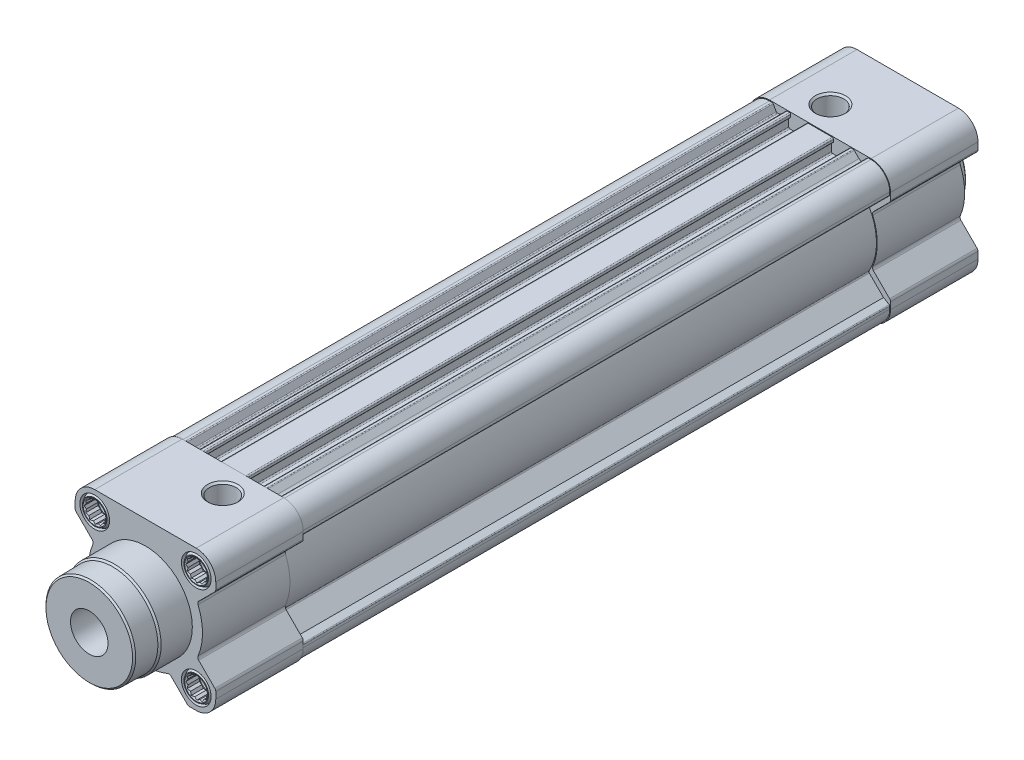
from build123d import *

# Parameters (mm, degrees)
BOSS_EXTRUDE1_DEPTH  = 28
BOSS_EXTRUDE2_DEPTH  = 188
SKETCH3_W            = 54
SKETCH3_H            = 54
CUT_EXTRUDE1_DEPTH   = 188
BOSS_EXTRUDE3_DEPTH  = 28
SKETCH7_W            = 21
SKETCH7_H            = 4.75
LPATTERN1_COUNT      = 2
LPATTERN1_PITCH      = 32.5
LPATTERN1_COUNT_DIR2 = 2
LPATTERN1_PITCH_DIR2 = 32.5
LPATTERN2_COUNT      = 2
LPATTERN2_PITCH      = 32.5
LPATTERN2_COUNT_DIR2 = 2
LPATTERN2_PITCH_DIR2 = 32.5
CUT_EXTRUDE2_DEPTH   = 4
LPATTERN3_COUNT      = 2
LPATTERN3_PITCH      = 32.5
LPATTERN3_COUNT_DIR2 = 2
LPATTERN3_PITCH_DIR2 = 32.5
LPATTERN4_COUNT      = 2
LPATTERN4_PITCH      = 32.5
LPATTERN4_COUNT_DIR2 = 2
LPATTERN4_PITCH_DIR2 = 32.5
SKETCH17_W           = 21
SKETCH17_H           = 4.75
LPATTERN5_COUNT      = 2
LPATTERN5_PITCH      = 32.5
LPATTERN5_COUNT_DIR2 = 2
LPATTERN5_PITCH_DIR2 = 32.5
LPATTERN6_COUNT      = 2
LPATTERN6_PITCH      = 32.5
LPATTERN6_COUNT_DIR2 = 2
LPATTERN6_PITCH_DIR2 = 32.5
LPATTERN7_COUNT      = 2
LPATTERN7_PITCH      = 32.5
LPATTERN7_COUNT_DIR2 = 2
LPATTERN7_PITCH_DIR2 = 32.5
CUT_EXTRUDE3_DEPTH   = 4
LPATTERN8_COUNT      = 2
LPATTERN8_PITCH      = 32.5
LPATTERN8_COUNT_DIR2 = 2
LPATTERN8_PITCH_DIR2 = 32.5


with BuildPart() as part:
    # Sketch1 → Boss-Extrude1 (new body)
    with BuildSketch(Plane.XY.offset(-28)):
        with BuildLine():
            Line((-22.207106781, 13.368272016), (-17.028937595, 8.190102831))
            ThreePointArc((-17.028937595, 8.190102831), (-16.754625387, 7.674873005), (-16.814691422, 7.094268982))
            ThreePointArc((-16.814691422, 7.094268982), (-18.25, 0), (-16.814691422, -7.094268982))
            ThreePointArc((-16.814691422, -7.094268982), (-16.754625387, -7.674873005), (-17.028937595, -8.190102831))
            Line((-17.028937595, -8.190102831), (-22.207106781, -13.368272016))
            ThreePointArc((-22.207106781, -13.368272016), (-22.423879533, -13.692695365), (-22.5, -14.075378798))
            Line((-22.5, -14.075378798), (-22.5, -16.25))
            ThreePointArc((-22.5, -16.25), (-20.669417382, -20.669417382), (-16.25, -22.5))
            Line((-16.25, -22.5), (-14.075378798, -22.5))
            ThreePointArc((-14.075378798, -22.5), (-13.692695365, -22.423879533), (-13.368272016, -22.207106781))
            Line((-13.368272016, -22.207106781), (-8.190102831, -17.028937595))
            ThreePointArc((-8.190102831, -17.028937595), (-7.674873005, -16.754625387), (-7.094268982, -16.814691422))
            ThreePointArc((-7.094268982, -16.814691422), (0, -18.25), (7.094268982, -16.814691422))
            ThreePointArc((7.094268982, -16.814691422), (7.674873005, -16.754625387), (8.190102831, -17.028937595))
            Line((8.190102831, -17.028937595), (13.368272016, -22.207106781))
            ThreePointArc((13.368272016, -22.207106781), (13.692695365, -22.423879533), (14.075378798, -22.5))
            Line((14.075378798, -22.5), (16.25, -22.5))
            ThreePointArc((16.25, -22.5), (20.669417382, -20.669417382), (22.5, -16.25))
            Line((22.5, -16.25), (22.5, -14.075378798))
            ThreePointArc((22.5, -14.075378798), (22.423879533, -13.692695365), (22.207106781, -13.368272016))
            Line((22.207106781, -13.368272016), (17.028937595, -8.190102831))
            ThreePointArc((17.028937595, -8.190102831), (16.754625387, -7.674873005), (16.814691422, -7.094268982))
            ThreePointArc((16.814691422, -7.094268982), (18.25, 0), (16.814691422, 7.094268982))
            ThreePointArc((16.814691422, 7.094268982), (16.754625387, 7.674873005), (17.028937595, 8.190102831))
            Line((17.028937595, 8.190102831), (22.207106781, 13.368272016))
            ThreePointArc((22.207106781, 13.368272016), (22.423879533, 13.692695365), (22.5, 14.075378798))
            Line((22.5, 14.075378798), (22.5, 16.25))
            ThreePointArc((22.5, 16.25), (20.669417382, 20.669417382), (16.25, 22.5))
            Line((16.25, 22.5), (-16.25, 22.5))
            ThreePointArc((-16.25, 22.5), (-20.669417382, 20.669417382), (-22.5, 16.25))
            Line((-22.5, 16.25), (-22.5, 14.075378798))
            ThreePointArc((-22.5, 14.075378798), (-22.423879533, 13.692695365), (-22.207106781, 13.368272016))
        make_face()
    extrude(amount=BOSS_EXTRUDE1_DEPTH)

    # Sketch2 → Boss-Extrude2 (add)
    with BuildSketch(Plane.XY.offset(-28)):
        with BuildLine():
            Line((-22.25, 13.764718626), (-16.641027679, 8.155746305))
            ThreePointArc((-16.641027679, 8.155746305), (-16.502437125, 7.890478462), (-16.540180506, 7.59357813))
            ThreePointArc((-16.540180506, 7.59357813), (-18.2, 0), (-16.540180506, -7.59357813))
            ThreePointArc((-16.540180506, -7.59357813), (-16.502437125, -7.890478462), (-16.641027679, -8.155746305))
            Line((-16.641027679, -8.155746305), (-22.25, -13.764718626))
            Line((-22.25, -13.764718626), (-22.25, -16.25))
            ThreePointArc((-22.25, -16.25), (-20.492640687, -20.492640687), (-16.25, -22.25))
            Line((-16.25, -22.25), (-13.764718626, -22.25))
            Line((-13.764718626, -22.25), (-8.155746305, -16.641027679))
            ThreePointArc((-8.155746305, -16.641027679), (-7.890478462, -16.502437125), (-7.59357813, -16.540180506))
            ThreePointArc((-7.59357813, -16.540180506), (0, -18.2), (7.59357813, -16.540180506))
            ThreePointArc((7.59357813, -16.540180506), (7.890478462, -16.502437125), (8.155746305, -16.641027679))
            Line((8.155746305, -16.641027679), (13.764718626, -22.25))
            Line((13.764718626, -22.25), (16.25, -22.25))
            ThreePointArc((16.25, -22.25), (20.492640687, -20.492640687), (22.25, -16.25))
            Line((22.25, -16.25), (22.25, -13.764718626))
            Line((22.25, -13.764718626), (16.641027679, -8.155746305))
            ThreePointArc((16.641027679, -8.155746305), (16.502437125, -7.890478462), (16.540180506, -7.59357813))
            ThreePointArc((16.540180506, -7.59357813), (18.2, 0), (16.540180506, 7.59357813))
            ThreePointArc((16.540180506, 7.59357813), (16.502437125, 7.890478462), (16.641027679, 8.155746305))
            Line((16.641027679, 8.155746305), (22.25, 13.764718626))
            Line((22.25, 13.764718626), (22.25, 16.25))
            ThreePointArc((22.25, 16.25), (20.492640687, 20.492640687), (16.25, 22.25))
            Line((16.25, 22.25), (-16.25, 22.25))
            ThreePointArc((-16.25, 22.25), (-20.492640687, 20.492640687), (-22.25, 16.25))
            Line((-22.25, 16.25), (-22.25, 13.764718626))
        make_face()
    extrude(amount=-BOSS_EXTRUDE2_DEPTH)

    # Sketch3 → Cut-Extrude1 (cut)
    with BuildSketch(Plane.XY.offset(-28)):
        Rectangle(SKETCH3_W, SKETCH3_H)
        with BuildLine():
            Line((-22.05, 15.063462134), (-20.287966634, 14.046151696))
            ThreePointArc((-20.287966634, 14.046151696), (-20.244462062, 14.017082871), (-20.205123922, 13.982584247))
            Line((-20.205123922, 13.982584247), (-15.725547462, 9.503007788))
            ThreePointArc((-15.725547462, 9.503007788), (-15.58358527, 9.21626987), (-15.644530559, 8.902171846))
            ThreePointArc((-15.644530559, 8.902171846), (-18, 0), (-15.644530559, -8.902171846))
            ThreePointArc((-15.644530559, -8.902171846), (-15.58358527, -9.21626987), (-15.725547462, -9.503007788))
            Line((-15.725547462, -9.503007788), (-20.242360871, -14.019821197))
            Line((-20.242360871, -14.019821197), (-22.05, -15.063462134))
            ThreePointArc((-22.05, -15.063462134), (-22.196410162, -15.209872296), (-22.25, -15.409872296))
            Line((-22.25, -15.409872296), (-22.25, -16.25))
            ThreePointArc((-22.25, -16.25), (-20.492640687, -20.492640687), (-16.25, -22.25))
            Line((-16.25, -22.25), (-15.409872296, -22.25))
            ThreePointArc((-15.409872296, -22.25), (-15.209872296, -22.196410162), (-15.063462134, -22.05))
            Line((-15.063462134, -22.05), (-14.046151696, -20.287966634))
            ThreePointArc((-14.046151696, -20.287966634), (-14.017082871, -20.244462062), (-13.982584247, -20.205123922))
            Line((-13.982584247, -20.205123922), (-9.503007788, -15.725547462))
            ThreePointArc((-9.503007788, -15.725547462), (-9.21626987, -15.58358527), (-8.902171846, -15.644530559))
            ThreePointArc((-8.902171846, -15.644530559), (0, -18), (8.902171846, -15.644530559))
            ThreePointArc((8.902171846, -15.644530559), (9.21626987, -15.58358527), (9.503007788, -15.725547462))
            Line((9.503007788, -15.725547462), (13.982584247, -20.205123922))
            ThreePointArc((13.982584247, -20.205123922), (14.017082871, -20.244462062), (14.046151696, -20.287966634))
            Line((14.046151696, -20.287966634), (15.063462134, -22.05))
            ThreePointArc((15.063462134, -22.05), (15.209872296, -22.196410162), (15.409872296, -22.25))
            Line((15.409872296, -22.25), (16.25, -22.25))
            ThreePointArc((16.25, -22.25), (20.492640687, -20.492640687), (22.25, -16.25))
            Line((22.25, -16.25), (22.25, -15.409872296))
            ThreePointArc((22.25, -15.409872296), (22.196410162, -15.209872296), (22.05, -15.063462134))
            Line((22.05, -15.063462134), (20.242360871, -14.019821197))
            Line((20.242360871, -14.019821197), (15.725547462, -9.503007788))
            ThreePointArc((15.725547462, -9.503007788), (15.58358527, -9.21626987), (15.644530559, -8.902171846))
            ThreePointArc((15.644530559, -8.902171846), (18, 0), (15.644530559, 8.902171846))
            ThreePointArc((15.644530559, 8.902171846), (15.58358527, 9.21626987), (15.725547462, 9.503007788))
            Line((15.725547462, 9.503007788), (20.205123922, 13.982584247))
            ThreePointArc((20.205123922, 13.982584247), (20.244462062, 14.017082871), (20.287966634, 14.046151696))
            Line((20.287966634, 14.046151696), (22.05, 15.063462134))
            ThreePointArc((22.05, 15.063462134), (22.196410162, 15.209872296), (22.25, 15.409872296))
            Line((22.25, 15.409872296), (22.25, 16.25))
            ThreePointArc((22.25, 16.25), (20.492640687, 20.492640687), (16.25, 22.25))
            Line((16.25, 22.25), (15.409872296, 22.25))
            ThreePointArc((15.409872296, 22.25), (15.209872296, 22.196410162), (15.063462134, 22.05))
            Line((15.063462134, 22.05), (14.081966677, 20.35))
            ThreePointArc((14.081966677, 20.35), (13.935556515, 20.203589838), (13.735556515, 20.15))
            Line((13.735556515, 20.15), (13.471320344, 20.15))
            ThreePointArc((13.471320344, 20.15), (12.897295195, 20.264180701), (12.410660172, 20.589339828))
            Line((12.410660172, 20.589339828), (10.867157288, 22.132842712))
            ThreePointArc((10.867157288, 22.132842712), (10.737387948, 22.219551813), (10.584314575, 22.25))
            Line((10.584314575, 22.25), (9.85, 22.25))
            ThreePointArc((9.85, 22.25), (9.567157288, 22.132842712), (9.45, 21.85))
            Line((9.45, 21.85), (9.45, 21.15))
            ThreePointArc((9.45, 21.15), (9.508578644, 21.008578644), (9.65, 20.95))
            Line((9.65, 20.95), (9.9, 20.95))
            ThreePointArc((9.9, 20.95), (10.041421356, 20.891421356), (10.1, 20.75))
            Line((10.1, 20.75), (10.1, 18.15))
            ThreePointArc((10.1, 18.15), (9.982842712, 17.867157288), (9.7, 17.75))
            Line((9.7, 17.75), (4, 17.75))
            ThreePointArc((4, 17.75), (3.717157288, 17.867157288), (3.6, 18.15))
            Line((3.6, 18.15), (3.6, 20.75))
            ThreePointArc((3.6, 20.75), (3.658578644, 20.891421356), (3.8, 20.95))
            Line((3.8, 20.95), (4.05, 20.95))
            ThreePointArc((4.05, 20.95), (4.191421356, 21.008578644), (4.25, 21.15))
            Line((4.25, 21.15), (4.25, 21.85))
            ThreePointArc((4.25, 21.85), (4.132842712, 22.132842712), (3.85, 22.25))
            Line((3.85, 22.25), (-3.85, 22.25))
            ThreePointArc((-3.85, 22.25), (-4.132842712, 22.132842712), (-4.25, 21.85))
            Line((-4.25, 21.85), (-4.25, 21.15))
            ThreePointArc((-4.25, 21.15), (-4.191421356, 21.008578644), (-4.05, 20.95))
            Line((-4.05, 20.95), (-3.8, 20.95))
            ThreePointArc((-3.8, 20.95), (-3.658578644, 20.891421356), (-3.6, 20.75))
            Line((-3.6, 20.75), (-3.6, 18.15))
            ThreePointArc((-3.6, 18.15), (-3.717157288, 17.867157288), (-4, 17.75))
            Line((-4, 17.75), (-9.7, 17.75))
            ThreePointArc((-9.7, 17.75), (-9.982842712, 17.867157288), (-10.1, 18.15))
            Line((-10.1, 18.15), (-10.1, 20.75))
            ThreePointArc((-10.1, 20.75), (-10.041421356, 20.891421356), (-9.9, 20.95))
            Line((-9.9, 20.95), (-9.65, 20.95))
            ThreePointArc((-9.65, 20.95), (-9.508578644, 21.008578644), (-9.45, 21.15))
            Line((-9.45, 21.15), (-9.45, 21.85))
            ThreePointArc((-9.45, 21.85), (-9.567157288, 22.132842712), (-9.85, 22.25))
            Line((-9.85, 22.25), (-10.584314575, 22.25))
            ThreePointArc((-10.584314575, 22.25), (-10.737387948, 22.219551813), (-10.867157288, 22.132842712))
            Line((-10.867157288, 22.132842712), (-12.410660172, 20.589339828))
            ThreePointArc((-12.410660172, 20.589339828), (-12.897295195, 20.264180701), (-13.471320344, 20.15))
            Line((-13.471320344, 20.15), (-13.735556515, 20.15))
            ThreePointArc((-13.735556515, 20.15), (-13.935556515, 20.203589838), (-14.081966677, 20.35))
            Line((-14.081966677, 20.35), (-15.063462134, 22.05))
            ThreePointArc((-15.063462134, 22.05), (-15.209872296, 22.196410162), (-15.409872296, 22.25))
            Line((-15.409872296, 22.25), (-16.25, 22.25))
            ThreePointArc((-16.25, 22.25), (-20.492640687, 20.492640687), (-22.25, 16.25))
            Line((-22.25, 16.25), (-22.25, 15.409872296))
            ThreePointArc((-22.25, 15.409872296), (-22.196410162, 15.209872296), (-22.05, 15.063462134))
        make_face(mode=Mode.SUBTRACT)
    extrude(amount=-CUT_EXTRUDE1_DEPTH, mode=Mode.SUBTRACT)

    # Sketch4 → Boss-Extrude3 (add)
    with BuildSketch(Plane.XY.offset(-244)):
        with BuildLine():
            Line((-22.207106781, 13.368272016), (-17.028937595, 8.190102831))
            ThreePointArc((-17.028937595, 8.190102831), (-16.754625387, 7.674873005), (-16.814691422, 7.094268982))
            ThreePointArc((-16.814691422, 7.094268982), (-18.25, 0), (-16.814691422, -7.094268982))
            ThreePointArc((-16.814691422, -7.094268982), (-16.754625387, -7.674873005), (-17.028937595, -8.190102831))
            Line((-17.028937595, -8.190102831), (-22.207106781, -13.368272016))
            ThreePointArc((-22.207106781, -13.368272016), (-22.423879533, -13.692695365), (-22.5, -14.075378798))
            Line((-22.5, -14.075378798), (-22.5, -16.25))
            ThreePointArc((-22.5, -16.25), (-20.669417382, -20.669417382), (-16.25, -22.5))
            Line((-16.25, -22.5), (-14.075378798, -22.5))
            ThreePointArc((-14.075378798, -22.5), (-13.692695365, -22.423879533), (-13.368272016, -22.207106781))
            Line((-13.368272016, -22.207106781), (-8.190102831, -17.028937595))
            ThreePointArc((-8.190102831, -17.028937595), (-7.674873005, -16.754625387), (-7.094268982, -16.814691422))
            ThreePointArc((-7.094268982, -16.814691422), (0, -18.25), (7.094268982, -16.814691422))
            ThreePointArc((7.094268982, -16.814691422), (7.674873005, -16.754625387), (8.190102831, -17.028937595))
            Line((8.190102831, -17.028937595), (13.368272016, -22.207106781))
            ThreePointArc((13.368272016, -22.207106781), (13.692695365, -22.423879533), (14.075378798, -22.5))
            Line((14.075378798, -22.5), (16.25, -22.5))
            ThreePointArc((16.25, -22.5), (20.669417382, -20.669417382), (22.5, -16.25))
            Line((22.5, -16.25), (22.5, -14.075378798))
            ThreePointArc((22.5, -14.075378798), (22.423879533, -13.692695365), (22.207106781, -13.368272016))
            Line((22.207106781, -13.368272016), (17.028937595, -8.190102831))
            ThreePointArc((17.028937595, -8.190102831), (16.754625387, -7.674873005), (16.814691422, -7.094268982))
            ThreePointArc((16.814691422, -7.094268982), (18.25, 0), (16.814691422, 7.094268982))
            ThreePointArc((16.814691422, 7.094268982), (16.754625387, 7.674873005), (17.028937595, 8.190102831))
            Line((17.028937595, 8.190102831), (22.207106781, 13.368272016))
            ThreePointArc((22.207106781, 13.368272016), (22.423879533, 13.692695365), (22.5, 14.075378798))
            Line((22.5, 14.075378798), (22.5, 16.25))
            ThreePointArc((22.5, 16.25), (20.669417382, 20.669417382), (16.25, 22.5))
            Line((16.25, 22.5), (-16.25, 22.5))
            ThreePointArc((-16.25, 22.5), (-20.669417382, 20.669417382), (-22.5, 16.25))
            Line((-22.5, 16.25), (-22.5, 14.075378798))
            ThreePointArc((-22.5, 14.075378798), (-22.423879533, 13.692695365), (-22.207106781, 13.368272016))
        make_face()
    extrude(amount=BOSS_EXTRUDE3_DEPTH)

    # Sketch5 → Revolve1 (revolve)
    with BuildSketch(Plane(origin=(0, 0, 0), x_dir=(0, 0, -1), z_dir=(1, 0, 0))):
        Polygon((-18, 0), (-18, 13.869087013), (-17.5, 14.369087013), (-10.508882578, 14.491117422), (-10, 15), (0, 15), (0, 0), align=None)
    revolve(axis=Axis((0, 0, 0), (0, 0, 1)))

    # Sketch6 → Cut-Revolve1 (revolve, cut)
    with BuildSketch(Plane(origin=(5.25, 0, 0), x_dir=(0, 0, -1), z_dir=(1, 0, 0))):
        Polygon((19.5, 22.5), (24.364, 22.5), (23.783, 21.919), (23.783, 0), (19.5, 0), align=None)
    revolve(axis=Axis((5.25, 0, -19.5), (0, 1, 0)), mode=Mode.SUBTRACT)

    # Sketch7 → Cut-Revolve2 (revolve, cut)
    with BuildSketch(Plane(origin=(16.25, 0, 0), x_dir=(0, 0, -1), z_dir=(1, 0, 0))):
        with Locations((10.5, 18.625)):
            Rectangle(SKETCH7_W, SKETCH7_H)
    cut_revolve2 = revolve(axis=Axis((16.25, 16.25, -21), (0, 0, 1)), mode=Mode.SUBTRACT)

    # LPattern1: Cut-Revolve2 2 × 2
    with Locations(*[(-i * LPATTERN1_PITCH, -j * LPATTERN1_PITCH_DIR2, 0) for i in range(LPATTERN1_COUNT) for j in range(LPATTERN1_COUNT_DIR2) if (i, j) != (0, 0)]):
        add(cut_revolve2, mode=Mode.SUBTRACT)

    # Sketch9 → Revolve2 (revolve)
    with BuildSketch(Plane(origin=(16.25, 0, 0), x_dir=(0, 0, -1), z_dir=(1, 0, 0))):
        Polygon((0, 16.25), (0, 20.172649731), (1, 20.75), (21, 20.75), (21, 16.25), align=None)
    revolve2 = revolve(axis=Axis((16.25, 16.25, -21), (0, 0, 1)))

    # LPattern2: Revolve2 2 × 2
    with Locations(*[(-i * LPATTERN2_PITCH, -j * LPATTERN2_PITCH_DIR2, 0) for i in range(LPATTERN2_COUNT) for j in range(LPATTERN2_COUNT_DIR2) if (i, j) != (0, 0)]):
        add(revolve2)

    # Sketch11 → Cut-Revolve3 (revolve, cut)
    with BuildSketch(Plane(origin=(16.25, 0, 0), x_dir=(0, 0, -1), z_dir=(1, 0, 0))):
        Polygon((0, 16.25), (0, 19.95), (0.404145188, 19.25), (5.5, 19.25), (6.0415, 18.7085), (18.7, 18.7085), (20.119415637, 16.25), align=None)
    cut_revolve3 = revolve(axis=Axis((16.25, 16.25, -20.119415637), (0, 0, 1)), mode=Mode.SUBTRACT)

    # Sketch12 → Cut-Extrude2 (cut, symmetric)
    with BuildSketch(Plane.XY):
        Polygon((12.785898385, 16.25), (13.25, 15.446152423), (13.25, 14.517949192), (14.053847577, 14.053847577), (14.517949192, 13.25), (15.446152423, 13.25), (16.25, 12.785898385), (17.053847577, 13.25), (17.982050808, 13.25), (18.446152423, 14.053847577), (19.25, 14.517949192), (19.25, 15.446152423), (19.714101615, 16.25), (19.25, 17.053847577), (19.25, 17.982050808), (18.446152423, 18.446152423), (17.982050808, 19.25), (17.053847577, 19.25), (16.25, 19.714101615), (15.446152423, 19.25), (14.517949192, 19.25), (14.053847577, 18.446152423), (13.25, 17.982050808), (13.25, 17.053847577), align=None)
    cut_extrude2 = extrude(amount=CUT_EXTRUDE2_DEPTH, both=True, mode=Mode.SUBTRACT)

    # LPattern3: Cut-Revolve3 2 × 2
    with Locations(*[(-i * LPATTERN3_PITCH, -j * LPATTERN3_PITCH_DIR2, 0) for i in range(LPATTERN3_COUNT) for j in range(LPATTERN3_COUNT_DIR2) if (i, j) != (0, 0)]):
        add(cut_revolve3, mode=Mode.SUBTRACT)

    # LPattern4: Cut-Extrude2 2 × 2
    with Locations(*[(-i * LPATTERN4_PITCH, -j * LPATTERN4_PITCH_DIR2, 0) for i in range(LPATTERN4_COUNT) for j in range(LPATTERN4_COUNT_DIR2) if (i, j) != (0, 0)]):
        add(cut_extrude2, mode=Mode.SUBTRACT)

    # Sketch15 → Revolve3 (revolve)
    with BuildSketch(Plane(origin=(0, 0, 0), x_dir=(0, 0, -1), z_dir=(1, 0, 0))):
        Polygon((244, 0), (244, 15), (247.5, 15), (248, 14.5), (248, 0), align=None)
    revolve(axis=Axis((0, 0, -248), (0, 0, 1)))

    # Sketch16 → Cut-Revolve4 (revolve, cut)
    with BuildSketch(Plane(origin=(-5.25, 0, 0), x_dir=(0, 0, -1), z_dir=(1, 0, 0))):
        Polygon((224.5, 22.5), (229.364, 22.5), (228.783, 21.919), (228.783, 0), (224.5, 0), align=None)
    revolve(axis=Axis((-5.25, 0, -224.5), (0, 1, 0)), mode=Mode.SUBTRACT)

    # Sketch17 → Cut-Revolve5 (revolve, cut)
    with BuildSketch(Plane(origin=(16.25, 0, 0), x_dir=(0, 0, -1), z_dir=(1, 0, 0))):
        with Locations((233.5, 18.625)):
            Rectangle(SKETCH17_W, SKETCH17_H)
    cut_revolve5 = revolve(axis=Axis((16.25, 16.25, -244), (0, 0, 1)), mode=Mode.SUBTRACT)

    # LPattern5: Cut-Revolve5 2 × 2
    with Locations(*[(-i * LPATTERN5_PITCH, -j * LPATTERN5_PITCH_DIR2, 0) for i in range(LPATTERN5_COUNT) for j in range(LPATTERN5_COUNT_DIR2) if (i, j) != (0, 0)]):
        add(cut_revolve5, mode=Mode.SUBTRACT)

    # Sketch19 → Revolve4 (revolve)
    with BuildSketch(Plane(origin=(16.25, 0, 0), x_dir=(0, 0, -1), z_dir=(1, 0, 0))):
        Polygon((223, 16.25), (223, 20.75), (243, 20.75), (244, 20.172649731), (244, 16.25), align=None)
    revolve4 = revolve(axis=Axis((16.25, 16.25, -244), (0, 0, 1)))

    # LPattern6: Revolve4 2 × 2
    with Locations(*[(-i * LPATTERN6_PITCH, -j * LPATTERN6_PITCH_DIR2, 0) for i in range(LPATTERN6_COUNT) for j in range(LPATTERN6_COUNT_DIR2) if (i, j) != (0, 0)]):
        add(revolve4)

    # Sketch21 → Cut-Revolve6 (revolve, cut)
    with BuildSketch(Plane(origin=(16.25, 0, 0), x_dir=(0, 0, -1), z_dir=(1, 0, 0))):
        Polygon((223.880584363, 16.25), (225.3, 18.7085), (237.9585, 18.7085), (238.5, 19.25), (243.595854812, 19.25), (244, 19.95), (244, 16.25), align=None)
    cut_revolve6 = revolve(axis=Axis((16.25, 16.25, -244), (0, 0, 1)), mode=Mode.SUBTRACT)

    # LPattern7: Cut-Revolve6 2 × 2
    with Locations(*[(-i * LPATTERN7_PITCH, -j * LPATTERN7_PITCH_DIR2, 0) for i in range(LPATTERN7_COUNT) for j in range(LPATTERN7_COUNT_DIR2) if (i, j) != (0, 0)]):
        add(cut_revolve6, mode=Mode.SUBTRACT)

    # Sketch23 → Cut-Extrude3 (cut, symmetric)
    with BuildSketch(Plane.XY.offset(-244)):
        Polygon((12.785898385, 16.25), (13.25, 15.446152423), (13.25, 14.517949192), (14.053847577, 14.053847577), (14.517949192, 13.25), (15.446152423, 13.25), (16.25, 12.785898385), (17.053847577, 13.25), (17.982050808, 13.25), (18.446152423, 14.053847577), (19.25, 14.517949192), (19.25, 15.446152423), (19.714101615, 16.25), (19.25, 17.053847577), (19.25, 17.982050808), (18.446152423, 18.446152423), (17.982050808, 19.25), (17.053847577, 19.25), (16.25, 19.714101615), (15.446152423, 19.25), (14.517949192, 19.25), (14.053847577, 18.446152423), (13.25, 17.982050808), (13.25, 17.053847577), align=None)
    cut_extrude3 = extrude(amount=CUT_EXTRUDE3_DEPTH, both=True, mode=Mode.SUBTRACT)

    # LPattern8: Cut-Extrude3 2 × 2
    with Locations(*[(-i * LPATTERN8_PITCH, -j * LPATTERN8_PITCH_DIR2, 0) for i in range(LPATTERN8_COUNT) for j in range(LPATTERN8_COUNT_DIR2) if (i, j) != (0, 0)]):
        add(cut_extrude3, mode=Mode.SUBTRACT)

    # Sketch25 → Cut-Revolve7 (revolve, cut)
    with BuildSketch(Plane(origin=(0, 0, 0), x_dir=(0, 0, -1), z_dir=(1, 0, 0))):
        Polygon((-18, 0), (-18, 6), (55.333333333, 6), (55.333333333, 16), (216, 16), (216, 0), align=None)
    revolve(axis=Axis((0, 0, -216), (0, 0, 1)), mode=Mode.SUBTRACT)


solid = part.part
